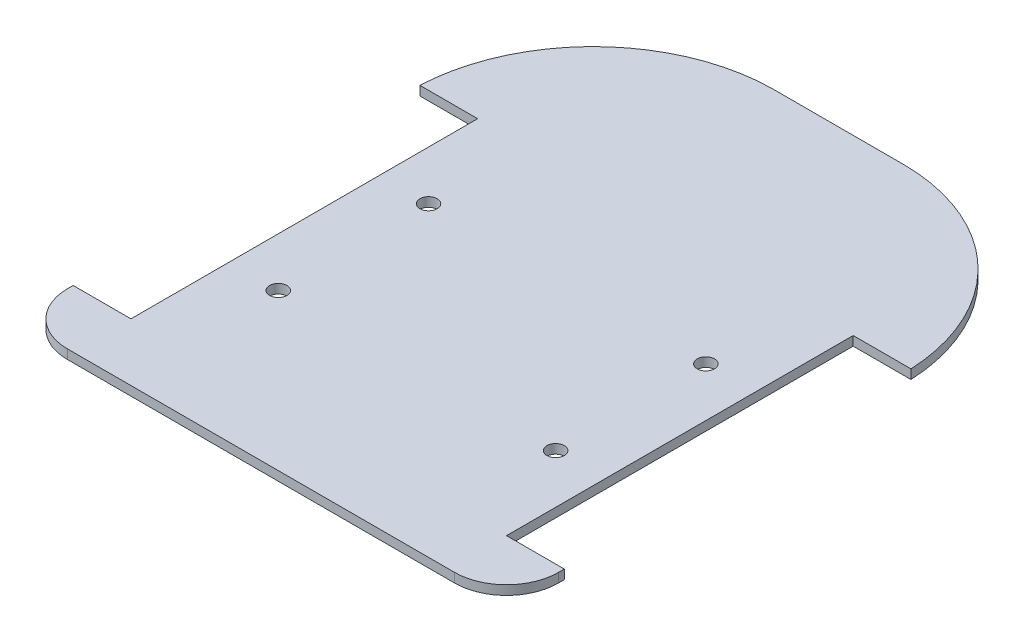
from build123d import *

# Parameters (mm, degrees)
BOSS_EXTRUDE1_DEPTH            = 1.6
SKETCH2_R                      = 1.5
CUT_EXTRUDE1_DEPTH             = 68.287145875
CUT_EXTRUDE4_REACH             = 69.287
SKETCH3_W                      = 5
SKETCH3_H                      = 100
CUT_EXTRUDE4_DIRECTION_2_DEPTH = 68.287145875


with BuildPart() as part:
    # Sketch1 → Boss-Extrude1 (new body)
    with BuildSketch(Plane(origin=(0, 0, 0), x_dir=(1, 0, 0), z_dir=(0, 1, 0))):
        with BuildLine():
            Line((-13.938774234, 50), (13.938774234, 50))
            ThreePointArc((13.938774234, 50), (35.432285481, 41.173831077), (45, 20))
            Line((45, 20), (35, 20))
            Line((35, 20), (35, -40))
            Line((35, -40), (45, -40))
            Line((45, -40), (45, -41))
            ThreePointArc((45, -41), (42.363961031, -47.363961031), (36, -50))
            Line((36, -50), (-36, -50))
            ThreePointArc((-36, -50), (-42.363961031, -47.363961031), (-45, -41))
            Line((-45, -41), (-45, -40))
            Line((-45, -40), (-35, -40))
            Line((-35, -40), (-35, 20))
            Line((-35, 20), (-45, 20))
            ThreePointArc((-45, 20), (-35.432285481, 41.173831077), (-13.938774234, 50))
        make_face()
    extrude(amount=BOSS_EXTRUDE1_DEPTH)

    # Sketch2 → Cut-Extrude1 (cut, through all)
    with BuildSketch(Plane(origin=(0, 1.6, 0), x_dir=(1, 0, 0), z_dir=(0, 1, 0))):
        with Locations(Location((-26.5, 3, 0), (0, 0, 270))):
            Circle(SKETCH2_R)
        with Locations(Location((-26.5, -23, 0), (0, 0, 270))):
            Circle(SKETCH2_R)
        with Locations(Location((26.5, -23, 0), (0, 0, 90))):
            Circle(SKETCH2_R)
        with Locations(Location((26.5, 3, 0), (0, 0, 90))):
            Circle(SKETCH2_R)
    extrude(amount=-CUT_EXTRUDE1_DEPTH, mode=Mode.SUBTRACT)

    # Sketch3 → Cut-Extrude4 (cut, up to next)
    with BuildSketch(Plane(origin=(0, 0, 0), x_dir=(1, 0, 0), z_dir=(0, 1, 0)), mode=Mode.PRIVATE) as cut_extrude4_sk1:
        Rectangle(SKETCH3_W, SKETCH3_H)
    cut_extrude4_tool1 = extrude(cut_extrude4_sk1.sketch, amount=CUT_EXTRUDE4_REACH, mode=Mode.PRIVATE) & part.part
    add(cut_extrude4_tool1.solids().sort_by_distance((0, 0, 0))[0], mode=Mode.SUBTRACT)

    # Sketch3 → Cut-Extrude4 direction 2 (cut)
    with BuildSketch(Plane(origin=(0, 0, 0), x_dir=(1, 0, 0), z_dir=(0, 1, 0))):
        Rectangle(SKETCH3_W, SKETCH3_H)
    extrude(amount=-CUT_EXTRUDE4_DIRECTION_2_DEPTH, mode=Mode.SUBTRACT)


with BuildPart() as cut_extrude4_piece_1:
    # of the separate pieces the step leaves, piece 1, a body of its own (cut_extrude4_pieces)
    add(part.part.solids().sort_by_distance((2.5, 0, -50))[0])


with BuildPart() as cut_extrude4_piece_2:
    # of the separate pieces the step leaves, piece 2, a body of its own (cut_extrude4_pieces)
    add(part.part.solids().sort_by_distance((-45, 0, -20))[0])


with BuildPart() as cut_extrude4_piece_2_1:
    # Body-Move/Copy1: moved
    add(cut_extrude4_piece_2.part.moved(Location((5, 0, 0))))


with BuildPart() as cut_extrude4_piece_1_1:
    add(cut_extrude4_piece_1.part)

    # Combine1: union Cut-Extrude4 piece 2
    add(cut_extrude4_piece_2_1.part)


solid = cut_extrude4_piece_1_1.part
